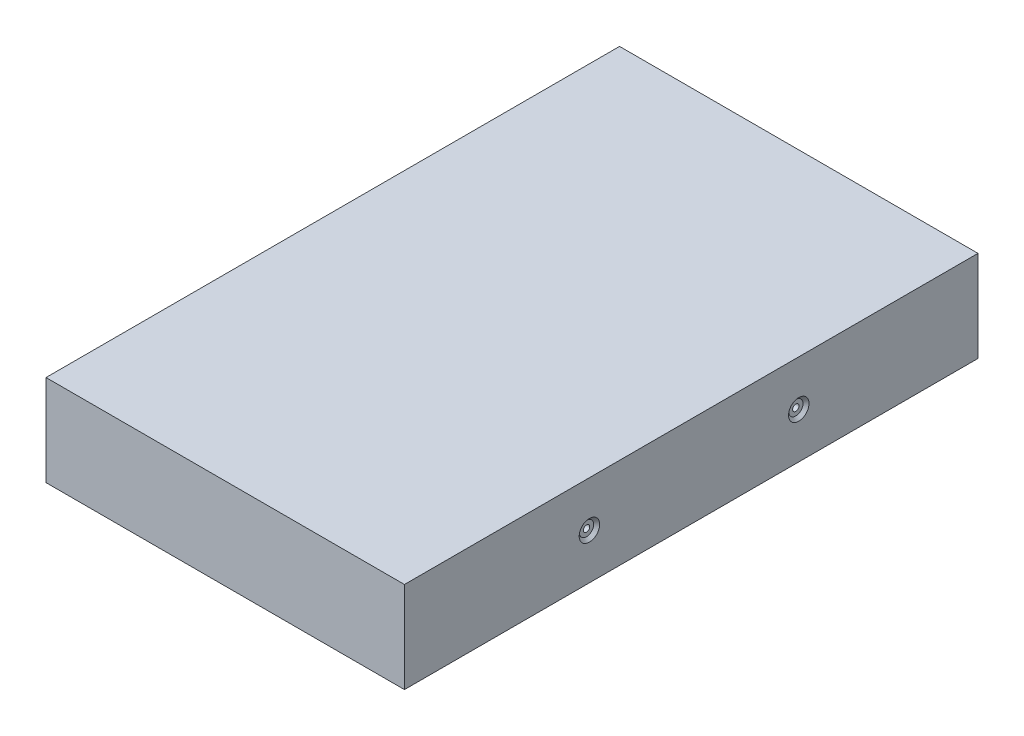
from build123d import *

# Parameters (mm, degrees)
SKETCH1_W                                   = 100
SKETCH1_H                                   = 160
BOSS_EXTRUDE1_DEPTH                         = 25.4
CBORE_FOR_0_BINDING_HEAD_MACHINE_SC_2_COUNT = 2
CBORE_FOR_0_BINDING_HEAD_MACHINE_SC_2_PITCH = 58.4


with BuildPart() as part:
    # Sketch1 → Boss-Extrude1 (new body)
    with BuildSketch(Plane(origin=(0, 0, 0), x_dir=(1, 0, 0), z_dir=(0, 1, 0))):
        Rectangle(SKETCH1_W, SKETCH1_H)
    extrude(amount=BOSS_EXTRUDE1_DEPTH)

    # Sketch3 → CBORE for #0 Binding Head Machine Screw1 (revolve, cut)
    with BuildSketch(Plane(origin=(50, 12.7, 28.4), x_dir=(0, 0, -1), z_dir=(0, 1, 0))):
        Polygon((0, 0), (0, 30.53416509), (0.889, 30), (0.889, 0.8128), (1.98501, 0.8128), (1.98501, 0.87249), (2.8575, 0), align=None)
    cbore_for_0_binding_head_machine_screw1 = revolve(axis=Axis((56.35, 12.7, 28.4), (-1, 0, 0)), mode=Mode.SUBTRACT)

    # CBORE for _0 Binding Head Machine Sc 2: CBORE for #0 Binding Head Machine Screw1 ×2
    with Locations(*[(0, 0, -i * CBORE_FOR_0_BINDING_HEAD_MACHINE_SC_2_PITCH) for i in range(1, CBORE_FOR_0_BINDING_HEAD_MACHINE_SC_2_COUNT)]):
        add(cbore_for_0_binding_head_machine_screw1, mode=Mode.SUBTRACT)


solid = part.part
